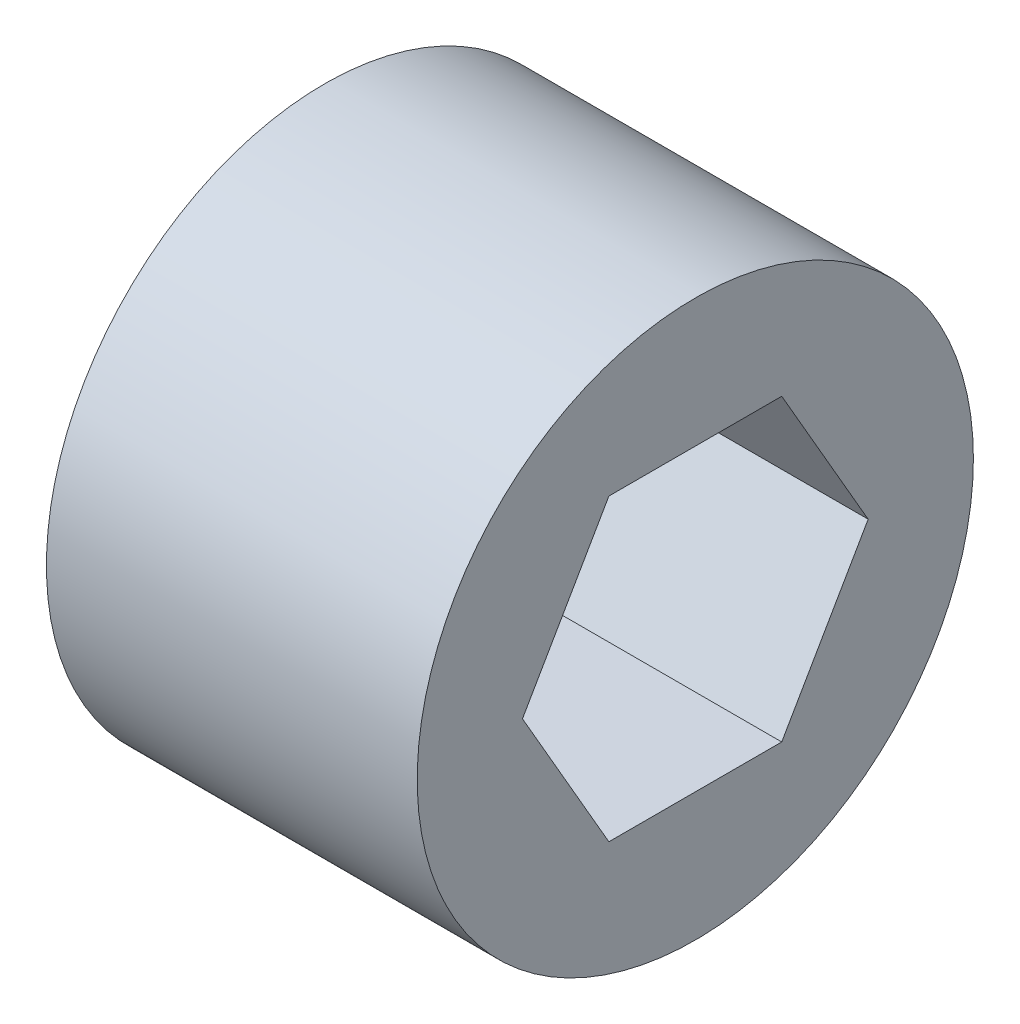
from build123d import *

# Parameters (mm, degrees)
SKETCH1_R           = 4.7625
BOSS_EXTRUDE1_DEPTH = 6.35


with BuildPart() as part:
    # Sketch1 → Boss-Extrude1 (new body)
    with BuildSketch(Plane(origin=(0, 0, 0), x_dir=(0, 0, -1), z_dir=(1, 0, 0))):
        Circle(SKETCH1_R)
        Polygon((1.480037388, 2.563499953), (-1.480037388, 2.563499953), (-2.960074776, 0), (-1.480037388, -2.563499953), (1.480037388, -2.563499953), (2.960074776, 0), align=None, mode=Mode.SUBTRACT)
    extrude(amount=BOSS_EXTRUDE1_DEPTH)


solid = part.part
